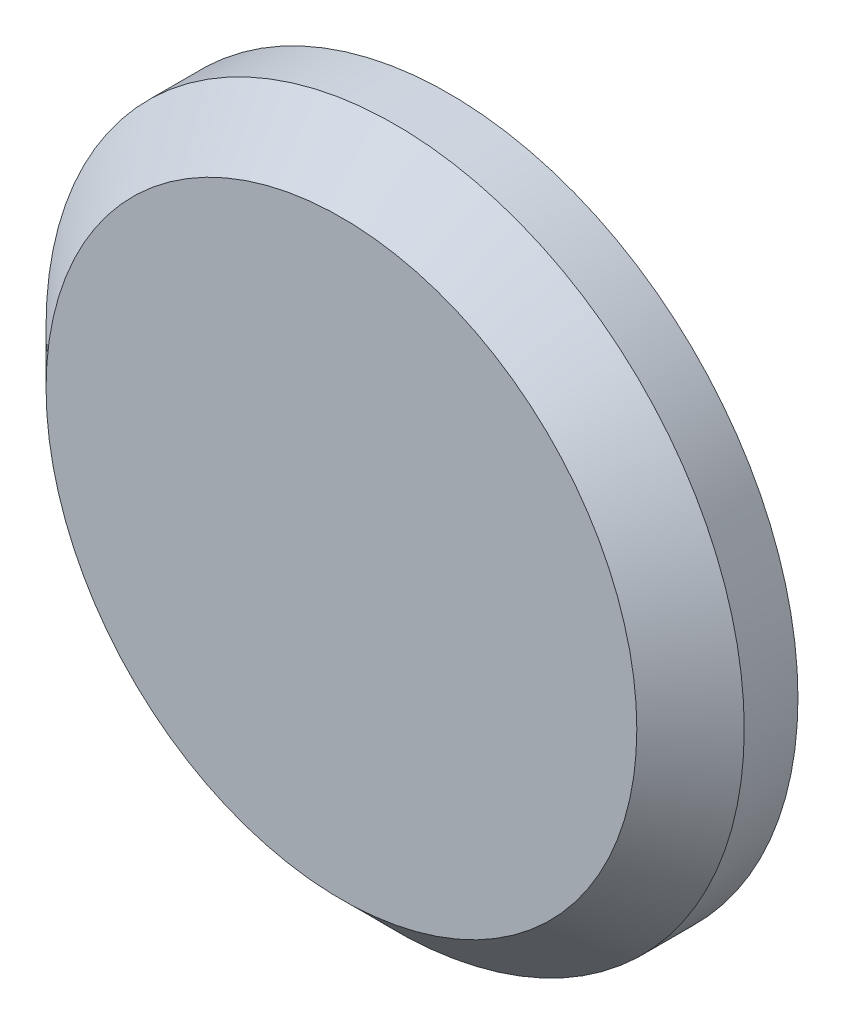
from build123d import *

# Parameters (mm, degrees)
SKETCH1_R           = 3.7
BOSS_EXTRUDE1_DEPTH = 10
SKETCH2_R           = 5
BOSS_EXTRUDE2_DEPTH = 2
SKETCH3_R           = 13
SKETCH3_R_2         = 4.1
BOSS_EXTRUDE3_DEPTH = 4
SKETCH4_R           = 21.887313971
CUT_EXTRUDE1_DEPTH  = 23
CHAMFER2_SIZE       = 2
SKETCH5_R           = 5.500381587
BOSS_EXTRUDE4_DEPTH = 1


with BuildPart() as part:
    # Sketch1 → Boss-Extrude1 (new body)
    with BuildSketch(Plane.XY):
        Circle(SKETCH1_R)
    extrude(amount=BOSS_EXTRUDE1_DEPTH)

    # Sketch2 → Boss-Extrude2 (add)
    with BuildSketch(Plane(origin=(0, 0, 0), x_dir=(-1, 0, 0), z_dir=(0, 0, -1))):
        Circle(SKETCH2_R)
    extrude(amount=BOSS_EXTRUDE2_DEPTH)

    # Sketch4 → Cut-Extrude1 (cut)
    with BuildSketch(Plane(origin=(0, 0, 10), x_dir=(-1, 0, 0), z_dir=(0, 0, -1))):
        with Locations((0, 0.481738505)):
            Circle(SKETCH4_R)
    extrude(amount=CUT_EXTRUDE1_DEPTH, mode=Mode.SUBTRACT)


with BuildPart() as body_2:
    # Sketch3 → Boss-Extrude3 (new body)
    with BuildSketch(Plane.XY.offset(10)):
        Circle(SKETCH3_R)
        Circle(SKETCH3_R_2, mode=Mode.SUBTRACT)
    extrude(amount=BOSS_EXTRUDE3_DEPTH)

    # Chamfer2
    chamfer2_edges = [body_2.edges().sort_by_distance(p)[0] for p in [
        (-13, 0, 14),
    ]]
    chamfer(chamfer2_edges, length=CHAMFER2_SIZE)

    # Sketch5 → Boss-Extrude4 (add)
    with BuildSketch(Plane.XY.offset(14)):
        Circle(SKETCH5_R)
    extrude(amount=-BOSS_EXTRUDE4_DEPTH)


solid = body_2.part
